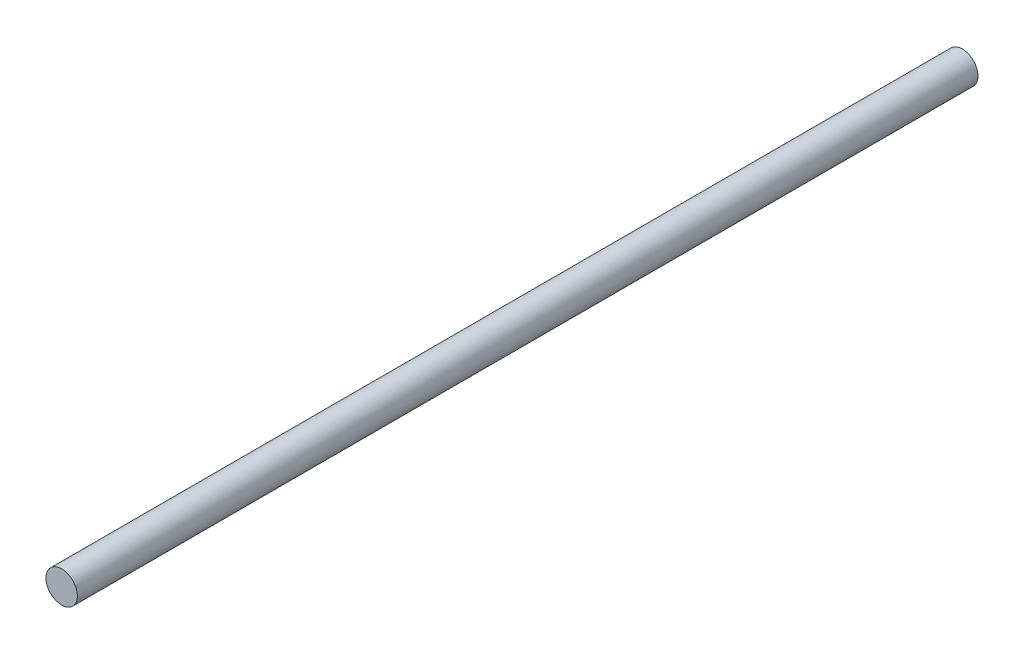
from build123d import *

# Parameters (mm, degrees)
SKETCH1_R           = 5
BOSS_EXTRUDE1_DEPTH = 286.9


with BuildPart() as part:
    # Sketch1 → Boss-Extrude1 (new body)
    with BuildSketch(Plane.XY):
        Circle(SKETCH1_R)
    extrude(amount=BOSS_EXTRUDE1_DEPTH)


solid = part.part
